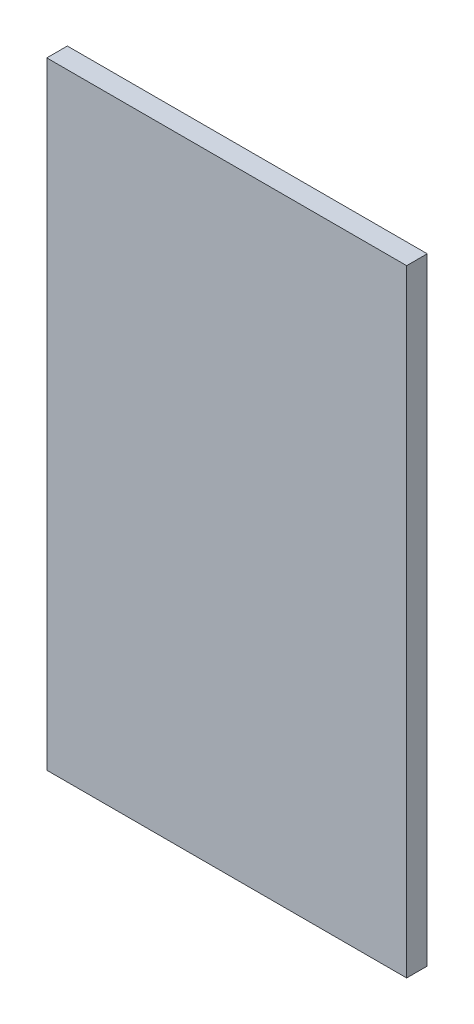
from build123d import *

# Parameters (mm, degrees)
SKETCH1_W           = 300
SKETCH1_H           = 175
BOSS_EXTRUDE1_DEPTH = 10


with BuildPart() as part:
    # Sketch1 → Boss-Extrude1 (new body)
    with BuildSketch(Plane(origin=(0, 0, 0), x_dir=(0, 1, 0), z_dir=(0, 0, 1))):
        Rectangle(SKETCH1_W, SKETCH1_H)
    extrude(amount=BOSS_EXTRUDE1_DEPTH)


solid = part.part
